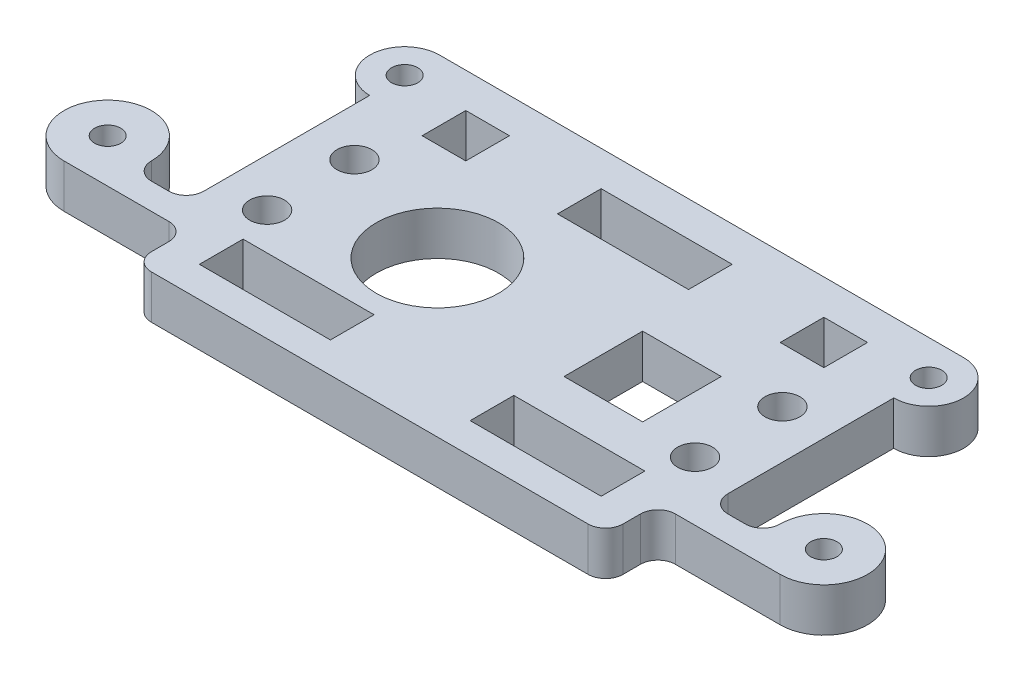
from build123d import *

# Parameters (mm, degrees)
SKETCH1_R           = 7
SKETCH1_R_2         = 1.5
SKETCH1_R_3         = 2
SKETCH1_W           = 5
SKETCH1_H           = 5
SKETCH1_W_2         = 15
SKETCH1_W_3         = 9
SKETCH1_H_2         = 9
BOSS_EXTRUDE1_DEPTH = 5


with BuildPart() as part:
    # Sketch1 → Boss-Extrude1 (new body)
    with BuildSketch(Plane(origin=(0, 0, 0), x_dir=(1, 0, 0), z_dir=(0, 1, 0))):
        with BuildLine():
            Line((-29, -11.75), (-30, -11.75))
            Line((-30, -11.75), (-41, -11.75))
            ThreePointArc((-41, -11.75), (-44.535533906, -3.214466094), (-36, -6.75))
            ThreePointArc((-36, -6.75), (-35.414213562, -8.164213562), (-34, -8.75))
            Line((-34, -8.75), (-32, -8.75))
            ThreePointArc((-32, -8.75), (-30.585786438, -8.164213562), (-30, -6.75))
            Line((-30, -6.75), (-30, 12.25))
            ThreePointArc((-30, 12.25), (-34, 16.25), (-30, 20.25))
            Line((-30, 20.25), (30, 20.25))
            ThreePointArc((30, 20.25), (34, 16.25), (30, 12.25))
            Line((30, 12.25), (30, -6.75))
            ThreePointArc((30, -6.75), (30.585786438, -8.164213562), (32, -8.75))
            Line((32, -8.75), (34, -8.75))
            ThreePointArc((34, -8.75), (35.414213562, -8.164213562), (36, -6.75))
            ThreePointArc((36, -6.75), (44.535533906, -3.214466094), (41, -11.75))
            Line((41, -11.75), (30, -11.75))
            Line((30, -11.75), (29, -11.75))
            ThreePointArc((29, -11.75), (27.585786438, -12.335786438), (27, -13.75))
            Line((27, -13.75), (27, -15.75))
            ThreePointArc((27, -15.75), (26.414213562, -17.164213562), (25, -17.75))
            Line((25, -17.75), (-25, -17.75))
            ThreePointArc((-25, -17.75), (-26.414213562, -17.164213562), (-27, -15.75))
            Line((-27, -15.75), (-27, -13.75))
            ThreePointArc((-27, -13.75), (-27.585786438, -12.335786438), (-29, -11.75))
        make_face()
        with Locations((-10, 0)):
            Circle(SKETCH1_R, mode=Mode.SUBTRACT)
        with Locations((-30, 16.25)):
            Circle(SKETCH1_R_2, mode=Mode.SUBTRACT)
        with Locations((30, 16.25)):
            Circle(SKETCH1_R_2, mode=Mode.SUBTRACT)
        with Locations((41, -6.75)):
            Circle(SKETCH1_R_2, mode=Mode.SUBTRACT)
        with Locations((-41, -6.75)):
            Circle(SKETCH1_R_2, mode=Mode.SUBTRACT)
        with Locations((-24.5, -5)):
            Circle(SKETCH1_R_3, mode=Mode.SUBTRACT)
        with Locations((24.5, -5)):
            Circle(SKETCH1_R_3, mode=Mode.SUBTRACT)
        with Locations((-24.5, 5)):
            Circle(SKETCH1_R_3, mode=Mode.SUBTRACT)
        with Locations((24.5, 5)):
            Circle(SKETCH1_R_3, mode=Mode.SUBTRACT)
        with Locations((-20.5, 13.75)):
            Rectangle(SKETCH1_W, SKETCH1_H, mode=Mode.SUBTRACT)
        with Locations((0, 13.75)):
            Rectangle(SKETCH1_W_2, SKETCH1_H, mode=Mode.SUBTRACT)
        with Locations((20.5, 13.75)):
            Rectangle(SKETCH1_W, SKETCH1_H, mode=Mode.SUBTRACT)
        with Locations((-15.5, -11.75)):
            Rectangle(SKETCH1_W_2, SKETCH1_H, mode=Mode.SUBTRACT)
        with Locations((15.5, -11.75)):
            Rectangle(SKETCH1_W_2, SKETCH1_H, mode=Mode.SUBTRACT)
        with Locations((13.5, 0)):
            Rectangle(SKETCH1_W_3, SKETCH1_H_2, mode=Mode.SUBTRACT)
    extrude(amount=BOSS_EXTRUDE1_DEPTH)


solid = part.part
